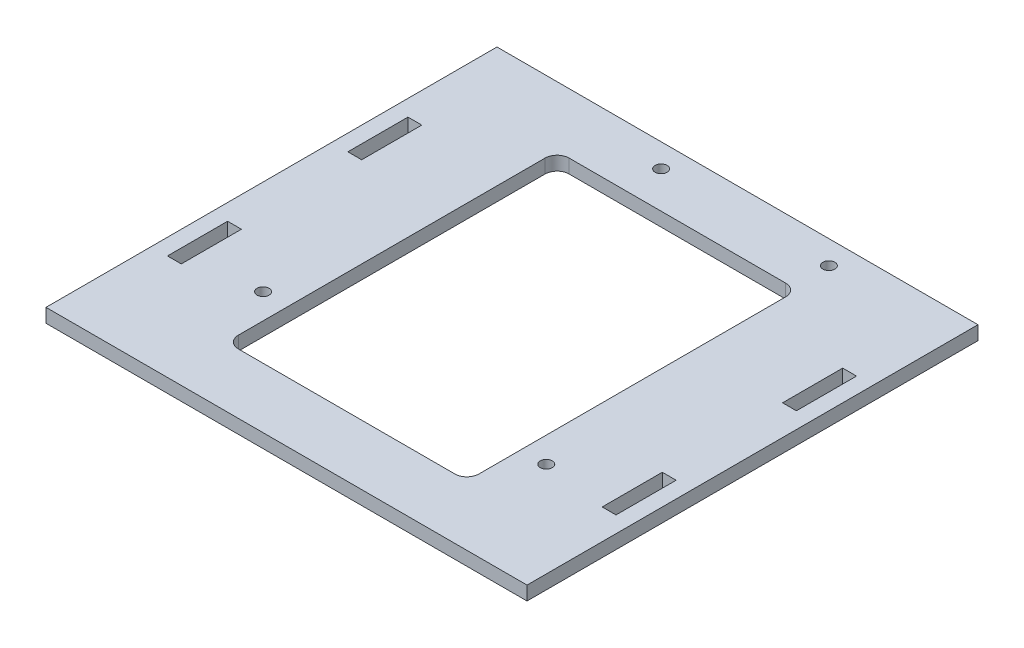
from build123d import *

# Parameters (mm, degrees)
SKETCH1_W           = 80
SKETCH1_H           = 75
BOSS_EXTRUDE1_DEPTH = 2.3
SKETCH2_W           = 2.3
SKETCH2_H           = 10
CUT_EXTRUDE1_DEPTH  = 10
SKETCH3_R           = 1
CUT_EXTRUDE2_DEPTH  = 10
CUT_EXTRUDE3_DEPTH  = 10
FILLET1_R           = 2


with BuildPart() as part:
    # Sketch1 → Boss-Extrude1 (new body)
    with BuildSketch(Plane(origin=(0, 0, 0), x_dir=(1, 0, 0), z_dir=(0, 1, 0))):
        with Locations((40, 37.5)):
            Rectangle(SKETCH1_W, SKETCH1_H)
    extrude(amount=BOSS_EXTRUDE1_DEPTH)

    # Sketch2 → Cut-Extrude1 (cut)
    with BuildSketch(Plane.XZ):
        with Locations((3.85, -52.5)):
            Rectangle(SKETCH2_W, SKETCH2_H)
        with Locations((3.85, -22.5)):
            Rectangle(SKETCH2_W, SKETCH2_H)
        with Locations((76.15, -52.5)):
            Rectangle(SKETCH2_W, SKETCH2_H)
        with Locations((76.15, -22.5)):
            Rectangle(SKETCH2_W, SKETCH2_H)
    extrude(amount=-CUT_EXTRUDE1_DEPTH, mode=Mode.SUBTRACT)

    # Sketch3 → Cut-Extrude2 (cut)
    with BuildSketch(Plane(origin=(0, 2.3, 0), x_dir=(1, 0, 0), z_dir=(0, 1, 0))):
        with Locations((31.2, 71.1)):
            Circle(SKETCH3_R)
        with Locations((59.1, 71.1)):
            Circle(SKETCH3_R)
        with Locations((15.8, 20.3)):
            Circle(SKETCH3_R)
        with Locations((64.2, 19)):
            Circle(SKETCH3_R)
    extrude(amount=-CUT_EXTRUDE2_DEPTH, mode=Mode.SUBTRACT)

    # Sketch4 → Cut-Extrude3 (cut)
    with BuildSketch(Plane(origin=(0, 2.3, 0), x_dir=(1, 0, 0), z_dir=(0, 1, 0))):
        Polygon((40, 10), (20, 10), (20, 65), (60, 65), (60, 10), align=None)
    extrude(amount=-CUT_EXTRUDE3_DEPTH, mode=Mode.SUBTRACT)

    # Fillet1
    fillet1_edges = [part.edges().sort_by_distance(p)[0] for p in [
        (60, 1.15, -10),
        (20, 1.15, -10),
        (20, 1.15, -65),
        (60, 1.15, -65),
    ]]
    fillet(fillet1_edges, radius=FILLET1_R)


solid = part.part
